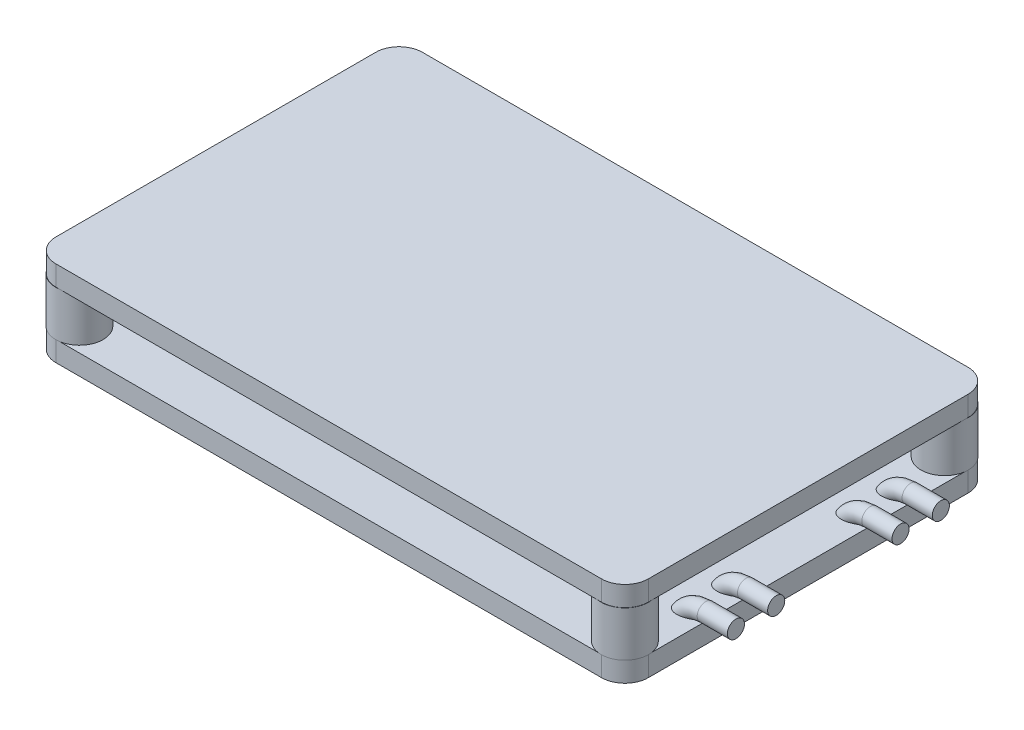
from build123d import *

# Parameters (mm, degrees)
BOSS_EXTRUDE1_DEPTH   = 2
SKETCH2_R             = 2.35
BOSS_EXTRUDE2_DEPTH   = 4.5
BOSS_EXTRUDE3_START   = 6.5
BOSS_EXTRUDE3_DEPTH   = 2
BOSS_EXTRUDE4_START   = 29.415
SKETCH4_R             = 0.85
BOSS_EXTRUDE4_DEPTH   = 3
BOSS_EXTRUDE4_2_DEPTH = 3
BOSS_EXTRUDE4_3_DEPTH = 3
BOSS_EXTRUDE4_4_DEPTH = 3
SKETCH5_R             = 0.85
REVOLVE2_ANGLE        = 90
BOSS_EXTRUDE5_START   = -29.415
SKETCH4_2_R           = 0.85
BOSS_EXTRUDE5_DEPTH   = 3
BOSS_EXTRUDE5_2_DEPTH = 3
SKETCH6_R             = 0.85
REVOLVE3_ANGLE        = 90


with BuildPart() as part:
    # Sketch1 → Boss-Extrude1 (new body)
    with BuildSketch(Plane(origin=(0, 0, 0), x_dir=(1, 0, 0), z_dir=(0, 1, 0))):
        with BuildLine():
            ThreePointArc((-29.415, -15.875), (-28.734023266, -17.519023266), (-27.09, -18.2))
            Line((-27.09, -18.2), (27.09, -18.2))
            ThreePointArc((27.09, -18.2), (28.734023266, -17.519023266), (29.415, -15.875))
            Line((29.415, -15.875), (29.415, 15.875))
            ThreePointArc((29.415, 15.875), (28.734023266, 17.519023266), (27.09, 18.2))
            Line((27.09, 18.2), (-27.09, 18.2))
            ThreePointArc((-27.09, 18.2), (-28.734023266, 17.519023266), (-29.415, 15.875))
            Line((-29.415, 15.875), (-29.415, -15.875))
        make_face()
    extrude(amount=BOSS_EXTRUDE1_DEPTH)

    # Sketch2 → Boss-Extrude2 (add)
    with BuildSketch(Plane(origin=(0, 2, 0), x_dir=(1, 0, 0), z_dir=(0, 1, 0))):
        with Locations(Location((-27.09, -15.875, 0), (0, 0, 171.635124732))):
            Circle(SKETCH2_R)
        with Locations(Location((-27.09, 15.875, 0), (0, 0, 81.635124732))):
            Circle(SKETCH2_R)
        with Locations(Location((27.09, 15.875, 0), (0, 0, 98.364875268))):
            Circle(SKETCH2_R)
        with Locations(Location((27.09, -15.875, 0), (0, 0, 8.364875268))):
            Circle(SKETCH2_R)
    extrude(amount=BOSS_EXTRUDE2_DEPTH)

    # Sketch1_3 → Boss-Extrude3 (add)
    with BuildSketch(Plane(origin=(0, 0, 0), x_dir=(1, 0, 0), z_dir=(0, 1, 0)).offset(BOSS_EXTRUDE3_START)):
        with BuildLine():
            ThreePointArc((-29.415, -15.875), (-28.734023266, -17.519023266), (-27.09, -18.2))
            Line((-27.09, -18.2), (27.09, -18.2))
            ThreePointArc((27.09, -18.2), (28.734023266, -17.519023266), (29.415, -15.875))
            Line((29.415, -15.875), (29.415, 15.875))
            ThreePointArc((29.415, 15.875), (28.734023266, 17.519023266), (27.09, 18.2))
            Line((27.09, 18.2), (-27.09, 18.2))
            ThreePointArc((-27.09, 18.2), (-28.734023266, 17.519023266), (-29.415, 15.875))
            Line((-29.415, 15.875), (-29.415, -15.875))
        make_face()
    extrude(amount=BOSS_EXTRUDE3_DEPTH)



with BuildPart() as body_2:
    # Sketch4 → Boss-Extrude4 (new body)
    with BuildSketch(Plane(origin=(0, 0, 0), x_dir=(0, 0, -1), z_dir=(1, 0, 0)).offset(BOSS_EXTRUDE4_START)):
        with Locations((10.175, 2.85)):
            Circle(SKETCH4_R)
    extrude(amount=BOSS_EXTRUDE4_DEPTH)


with BuildPart() as body_3:
    # Sketch4 → Boss-Extrude4 2 (new body)
    with BuildSketch(Plane(origin=(0, 0, 0), x_dir=(0, 0, -1), z_dir=(1, 0, 0)).offset(BOSS_EXTRUDE4_START)):
        with Locations((6.175, 2.85)):
            Circle(SKETCH4_R)
    extrude(amount=BOSS_EXTRUDE4_2_DEPTH)


with BuildPart() as body_4:
    # Sketch4 → Boss-Extrude4 3 (new body)
    with BuildSketch(Plane(origin=(0, 0, 0), x_dir=(0, 0, -1), z_dir=(1, 0, 0)).offset(BOSS_EXTRUDE4_START)):
        with Locations((-6.175, 2.85)):
            Circle(SKETCH4_R)
    extrude(amount=BOSS_EXTRUDE4_3_DEPTH)


with BuildPart() as body_5:
    # Sketch4 → Boss-Extrude4 4 (new body)
    with BuildSketch(Plane(origin=(0, 0, 0), x_dir=(0, 0, -1), z_dir=(1, 0, 0)).offset(BOSS_EXTRUDE4_START)):
        with Locations((-10.175, 2.85)):
            Circle(SKETCH4_R)
    extrude(amount=BOSS_EXTRUDE4_4_DEPTH)


with BuildPart() as part_1:
    add(part.part)

    add(body_2.part)  # Revolve2 merges body 2

    add(body_3.part)  # Revolve2 merges body 3

    add(body_4.part)  # Revolve2 merges body 4

    add(body_5.part)  # Revolve2 merges body 5
    # Sketch5 → Revolve2 (revolve)
    with BuildSketch(Plane.ZY.offset(-29.415)):
        with Locations(Location((10.175, 2.85, 0), (0, 0, 270))):
            Circle(SKETCH5_R)
        with Locations(Location((6.175, 2.85, 0), (0, 0, 270))):
            Circle(SKETCH5_R)
        with Locations(Location((-6.175, 2.85, 0), (0, 0, 270))):
            Circle(SKETCH5_R)
        with Locations(Location((-10.175, 2.85, 0), (0, 0, 270))):
            Circle(SKETCH5_R)
    revolve(axis=Axis((29.415, 0, 0), (0, 0, 1)), revolution_arc=REVOLVE2_ANGLE)



with BuildPart() as body_2_2:
    # Sketch4_2 → Boss-Extrude5 (new body)
    with BuildSketch(Plane(origin=(0, 0, 0), x_dir=(0, 0, -1), z_dir=(1, 0, 0)).offset(BOSS_EXTRUDE5_START)):
        with Locations(Location((6.175, 2.85, 0), (0, 0, 270))):
            Circle(SKETCH4_2_R)
    extrude(amount=-BOSS_EXTRUDE5_DEPTH)


with BuildPart() as body_3_2:
    # Sketch4_2 → Boss-Extrude5 2 (new body)
    with BuildSketch(Plane(origin=(0, 0, 0), x_dir=(0, 0, -1), z_dir=(1, 0, 0)).offset(BOSS_EXTRUDE5_START)):
        with Locations(Location((10.175, 2.85, 0), (0, 0, 270))):
            Circle(SKETCH4_2_R)
    extrude(amount=-BOSS_EXTRUDE5_2_DEPTH)


with BuildPart() as part_2:
    add(part_1.part)

    add(body_2_2.part)  # Revolve3 merges body 2 2

    add(body_3_2.part)  # Revolve3 merges body 3 2
    # Sketch6 → Revolve3 (revolve)
    with BuildSketch(Plane(origin=(-29.415, 0, 0), x_dir=(0, 0, -1), z_dir=(1, 0, 0))):
        with Locations(Location((10.175, 2.85, 0), (0, 0, 270))):
            Circle(SKETCH6_R)
        with Locations(Location((6.175, 2.85, 0), (0, 0, 270))):
            Circle(SKETCH6_R)
    revolve(axis=Axis((-29.415, 0, 0), (0, 0, -1)), revolution_arc=REVOLVE3_ANGLE)


solid = part_2.part
